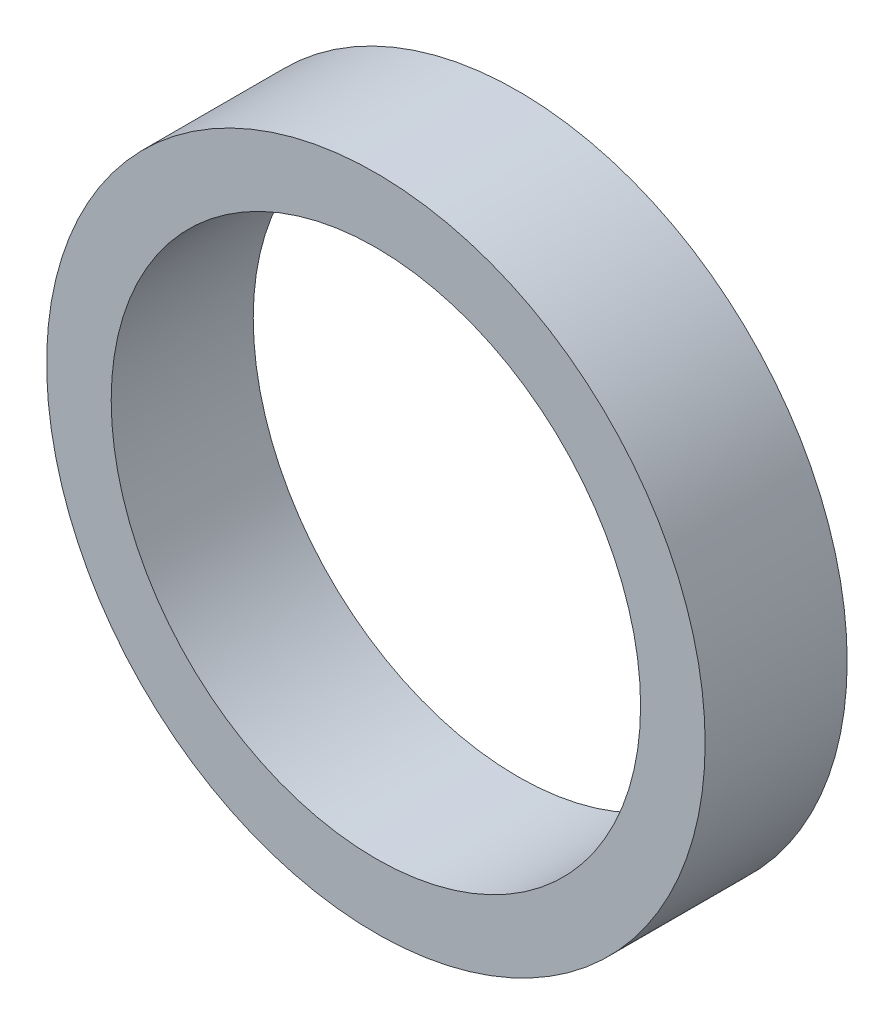
from build123d import *

# Parameters (mm, degrees)
SKETCH1_R           = 25.5
SKETCH1_R_2         = 20.5
BOSS_EXTRUDE1_DEPTH = 11


with BuildPart() as part:
    # Sketch1 → Boss-Extrude1 (new body)
    with BuildSketch(Plane.XY):
        Circle(SKETCH1_R)
        Circle(SKETCH1_R_2, mode=Mode.SUBTRACT)
    extrude(amount=BOSS_EXTRUDE1_DEPTH)


solid = part.part
